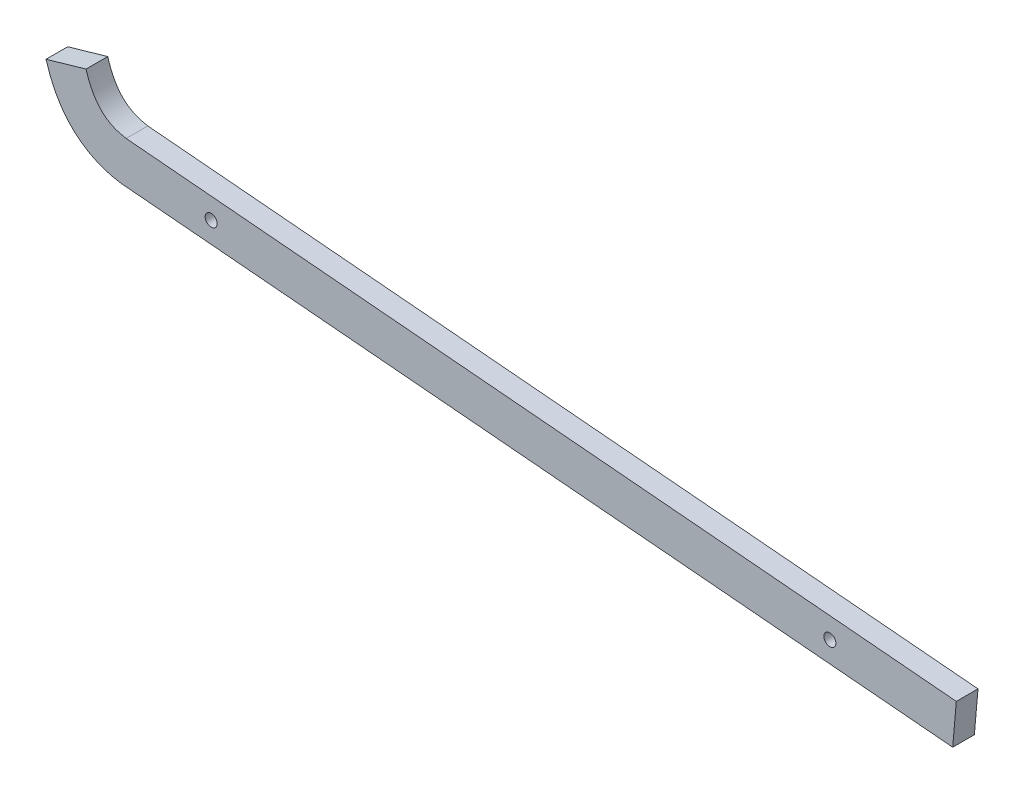
from build123d import *

# Parameters (mm, degrees)
BOSS_EXTRUDE1_DEPTH       = 6.604
F_6_CLEARANCE_HOLE1_D     = 3.6576
F_6_CLEARANCE_HOLE1_DEPTH = 10.16
F_6_CLEARANCE_HOLE1_TIP   = 1.0988539


with BuildPart() as part:
    # Sketch1 → Boss-Extrude1 (new body)
    with BuildSketch(Plane.XY):
        with BuildLine():
            Line((16.823092539, -23.059379431), (270.045750863, -45.152940848))
            Line((270.045750863, -45.152940848), (271.149626418, -32.501005867))
            Line((271.149626418, -32.501005867), (18.308001968, -10.440689482))
            add(Edge.make_bspline(
                [(6.100873241, 1.761205752), (6.243998722, 1.265414493), (6.562029623, 0.258197332), (7.239782187, -1.541714319), (8.191856686, -3.521031278), (9.459597024, -5.451591955), (10.839105985, -7.00109828), (12.345816988, -8.235279198), (14.031634784, -9.215214087), (15.656369367, -9.844087266), (17.105920915, -10.226590441), (17.911821211, -10.379141677), (18.308001968, -10.440689482)],
                knots=[0, 0, 0, 0, 0.061967329, 0.123934658, 0.247869317, 0.371803975, 0.495738633, 0.619673292, 0.74360795, 0.867542608, 0.929509938, 0.991477267, 0.991477267, 0.991477267, 0.991477267], degree=3))
            Line((6.100873241, 1.761205752), (-6.100873241, -1.761205752))
            add(Edge.make_bspline(
                [(-6.100873241, -1.761205752), (-5.89459242, -2.475769135), (-5.442695686, -3.905842246), (-4.417225036, -6.62638985), (-2.877642754, -9.827164342), (-0.591083482, -13.296598328), (3.065590072, -17.362765142), (7.603197402, -20.424150011), (12.110004519, -22.072207275), (14.454118771, -22.647767765), (15.661607343, -22.877150547), (16.252804896, -22.974574297), (16.621102903, -23.030106303), (16.751262737, -23.048877832), (16.823092539, -23.059379431)],
                knots=[0, 0, 0, 0, 0.062929816, 0.125859631, 0.251719262, 0.377578894, 0.503438525, 0.755157787, 0.881017419, 0.943947234, 0.975412142, 0.991144596, 0.999010823, 1.00687705, 1.00687705, 1.00687705, 1.00687705], degree=3))
        make_face()
    extrude(amount=BOSS_EXTRUDE1_DEPTH)

    # #6 Clearance Hole1
    with Locations(Plane.XY.offset(6.604)):
        with Locations((232.641883698, -35.515346692), (44.200873241, -19.073954498)):
            Hole(F_6_CLEARANCE_HOLE1_D / 2, depth=F_6_CLEARANCE_HOLE1_DEPTH)
            with Locations((0, 0, -(F_6_CLEARANCE_HOLE1_DEPTH + F_6_CLEARANCE_HOLE1_TIP / 2))):  # 118° drill point
                Cone(0, F_6_CLEARANCE_HOLE1_D / 2, F_6_CLEARANCE_HOLE1_TIP, mode=Mode.SUBTRACT)


solid = part.part
